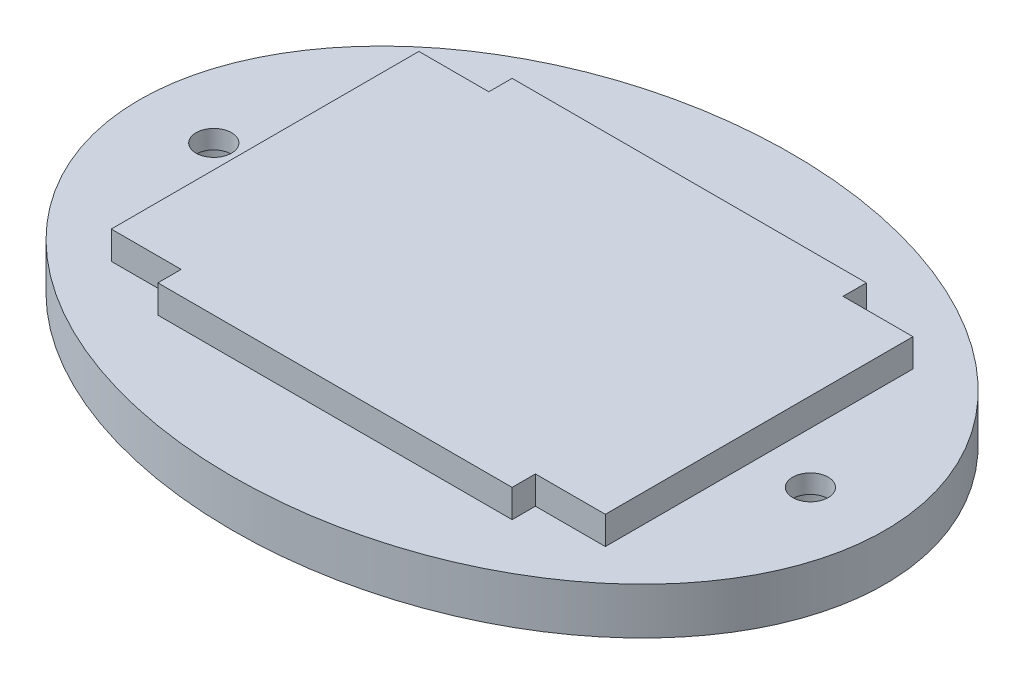
from build123d import *

# Parameters (mm, degrees)
SKETCH1_RX          = 40
SKETCH1_RY          = 30
BOSS_EXTRUDE1_DEPTH = 5
BOSS_EXTRUDE2_DEPTH = 3
SKETCH3_R           = 1.905
CUT_EXTRUDE1_DEPTH  = 10
SKETCH4_R           = 3.405
CUT_EXTRUDE2_DEPTH  = 3


with BuildPart() as part:
    # Sketch1 → Boss-Extrude1 (new body)
    with BuildSketch(Plane(origin=(0, 0, 0), x_dir=(1, 0, 0), z_dir=(0, 1, 0))):
        with Locations(Location((0, 0), (0, 0, 180))):
            Ellipse(SKETCH1_RX, SKETCH1_RY)
    extrude(amount=BOSS_EXTRUDE1_DEPTH)

    # Sketch2 → Boss-Extrude2 (add)
    with BuildSketch(Plane(origin=(0, 5, 0), x_dir=(1, 0, 0), z_dir=(0, 1, 0))):
        Polygon((-19, 16.5), (-26.5, 16.5), (-26.5, -16.5), (-19, -16.5), (-19, -19), (19, -19), (19, -16.5), (26.5, -16.5), (26.5, 16.5), (19, 16.5), (19, 19), (-19, 19), align=None)
    extrude(amount=BOSS_EXTRUDE2_DEPTH)

    # Sketch3 → Cut-Extrude1 (cut)
    with BuildSketch(Plane.XZ):
        with Locations((32, 0)):
            Circle(SKETCH3_R)
        with Locations((-32, 0)):
            Circle(SKETCH3_R)
    extrude(amount=-CUT_EXTRUDE1_DEPTH, mode=Mode.SUBTRACT)

    # Sketch4 → Cut-Extrude2 (cut)
    with BuildSketch(Plane.XZ):
        with Locations((-32, 0)):
            Circle(SKETCH4_R)
        with Locations((32, 0)):
            Circle(SKETCH4_R)
    extrude(amount=-CUT_EXTRUDE2_DEPTH, mode=Mode.SUBTRACT)


solid = part.part
